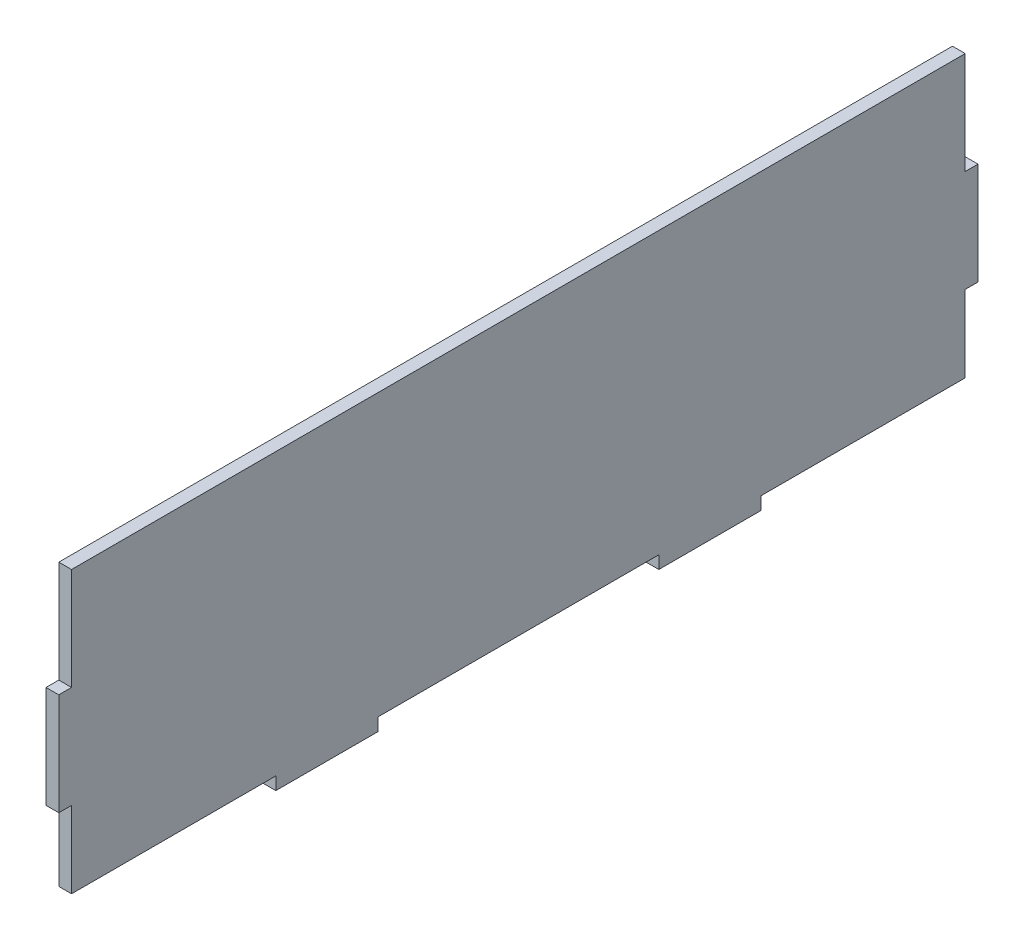
from build123d import *

# Parameters (mm, degrees)
BOSS_EXTRUDE1_DEPTH = 3.175


with BuildPart() as part:
    # Sketch1 → Boss-Extrude1 (new body)
    with BuildSketch(Plane(origin=(0, 0, 0), x_dir=(0, 0, -1), z_dir=(1, 0, 0))):
        Polygon((-116.659983875, 27.078998721), (-116.659983875, 1.678998721), (-119.834983875, 1.678998721), (-119.834983875, -23.721001279), (-116.659983875, -23.721001279), (-116.659983875, -42.771001279), (-65.859983875, -42.771001279), (-65.859983875, -45.946001279), (-40.459983875, -45.946001279), (-40.459983875, -42.771001279), (29.390016125, -42.771001279), (29.390016125, -45.946001279), (54.790016125, -45.946001279), (54.790016125, -42.771001279), (105.590016125, -42.771001279), (105.590016125, -23.721001279), (108.765016125, -23.721001279), (108.765016125, 1.678998721), (105.590016125, 1.678998721), (105.590016125, 27.078998721), align=None)
    extrude(amount=BOSS_EXTRUDE1_DEPTH)


solid = part.part
